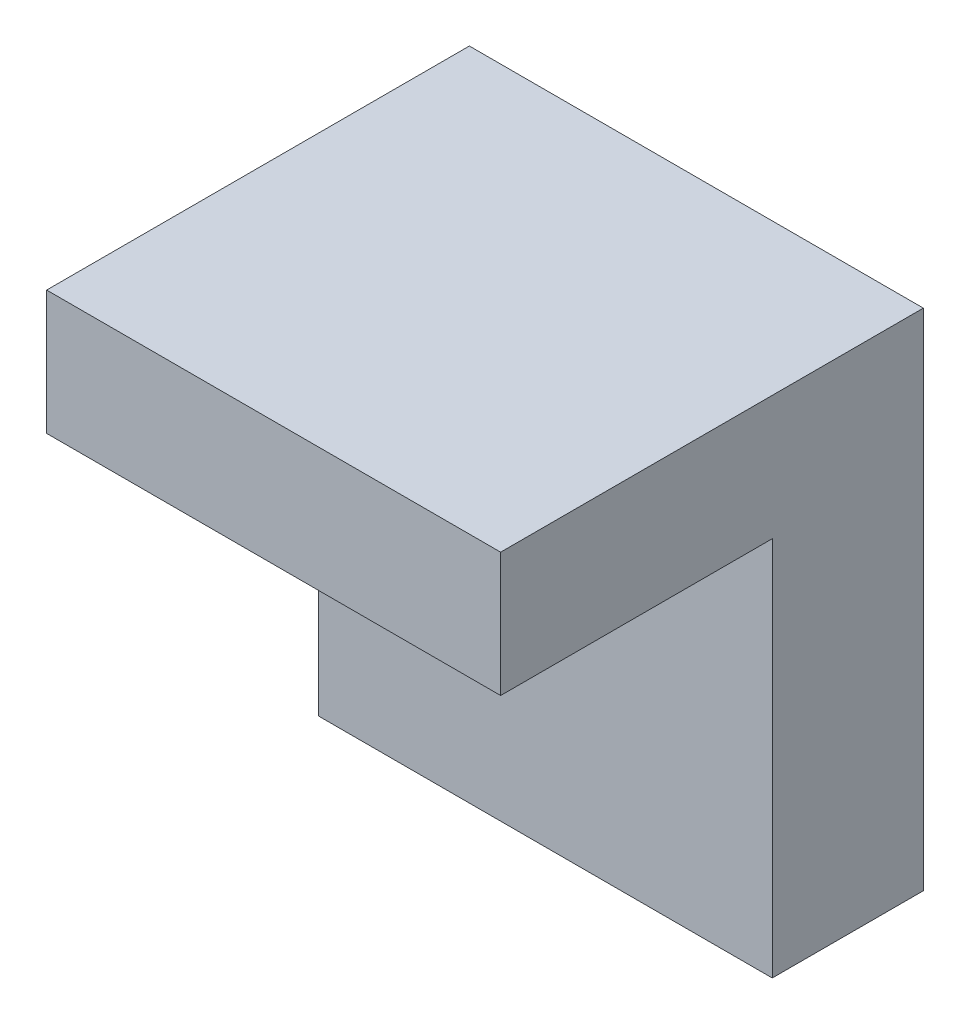
from build123d import *

# Parameters (mm, degrees)
SKETCH1_W           = 7
SKETCH1_H           = 3.2
BOSS_EXTRUDE1_DEPTH = 11.7


with BuildPart() as part:
    # Sketch1 → Boss-Extrude1 (new body)
    with BuildSketch(Plane(origin=(0, 0, 0), x_dir=(0, 0, -1), z_dir=(1, 0, 0))):
        Rectangle(SKETCH1_W, SKETCH1_H)
        Polygon((3.5, 1.6), (3.5, -1.6), (3.5, -11.404255319), (7.393617021, -11.404255319), (7.393617021, 1.6), align=None)
    extrude(amount=BOSS_EXTRUDE1_DEPTH)


solid = part.part
